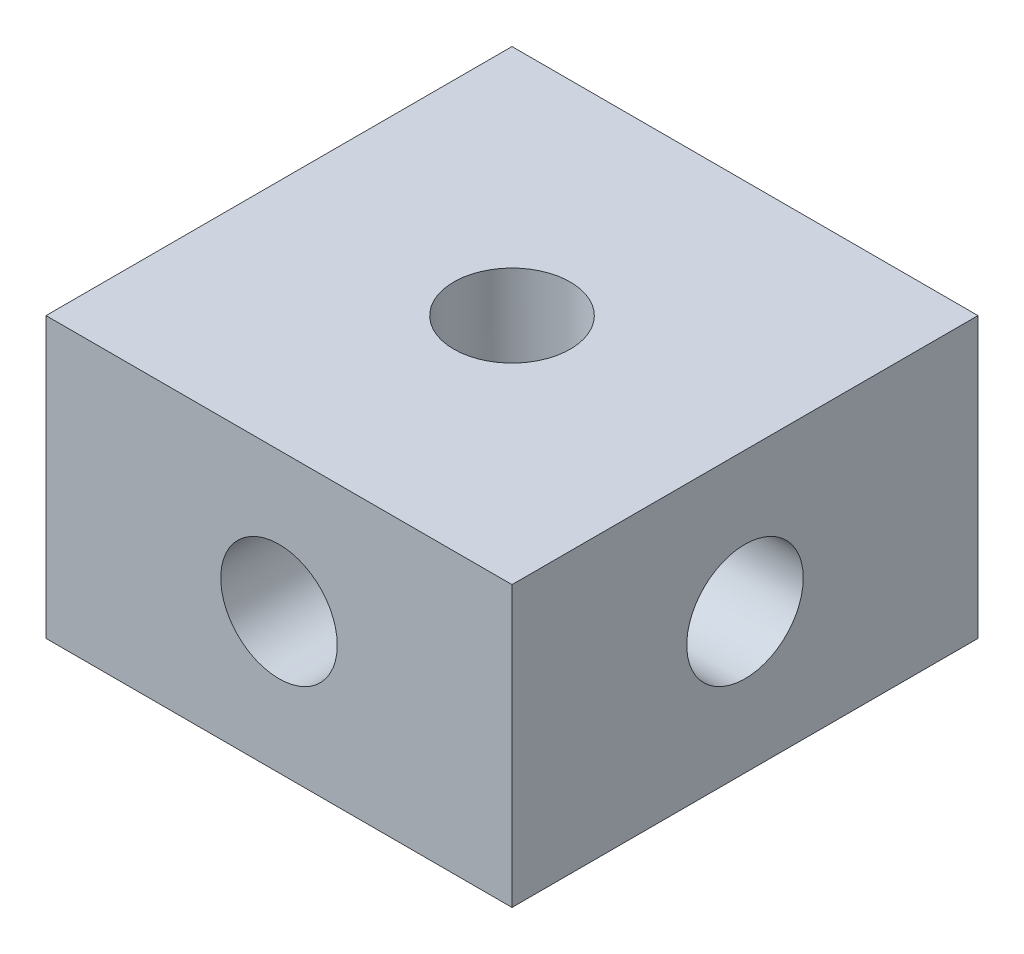
from build123d import *

# Parameters (mm, degrees)
SKETCH_1_W          = 10
SKETCH_1_H          = 10
EXTRUDE_1_DEPTH     = 3
SKETCH_2_R          = 1.25
CUT_EXTRUDE_1_DEPTH = 7
SKETCH_3_R          = 1.25
CUT_EXTRUDE_2_DEPTH = 11
SKETCH_4_R          = 1.25
CUT_EXTRUDE_3_DEPTH = 11


with BuildPart() as part:
    # 草圖1 → 填料-伸長1 (new body, symmetric)
    with BuildSketch(Plane(origin=(0, 0, 0), x_dir=(1, 0, 0), z_dir=(0, 1, 0))):
        Rectangle(SKETCH_1_W, SKETCH_1_H)
    extrude(amount=EXTRUDE_1_DEPTH, both=True)

    # 草圖2 → 除料-伸長1 (cut, through all)
    with BuildSketch(Plane(origin=(0, 3, 0), x_dir=(1, 0, 0), z_dir=(0, 1, 0))):
        Circle(SKETCH_2_R)
    extrude(amount=-CUT_EXTRUDE_1_DEPTH, mode=Mode.SUBTRACT)

    # 草圖3 → 除料-伸長2 (cut, through all)
    with BuildSketch(Plane.XY.offset(5)):
        Circle(SKETCH_3_R)
    extrude(amount=-CUT_EXTRUDE_2_DEPTH, mode=Mode.SUBTRACT)

    # 草圖4 → 除料-伸長3 (cut, through all)
    with BuildSketch(Plane(origin=(5, 0, 0), x_dir=(0, 0, -1), z_dir=(1, 0, 0))):
        Circle(SKETCH_4_R)
    extrude(amount=-CUT_EXTRUDE_3_DEPTH, mode=Mode.SUBTRACT)


solid = part.part
